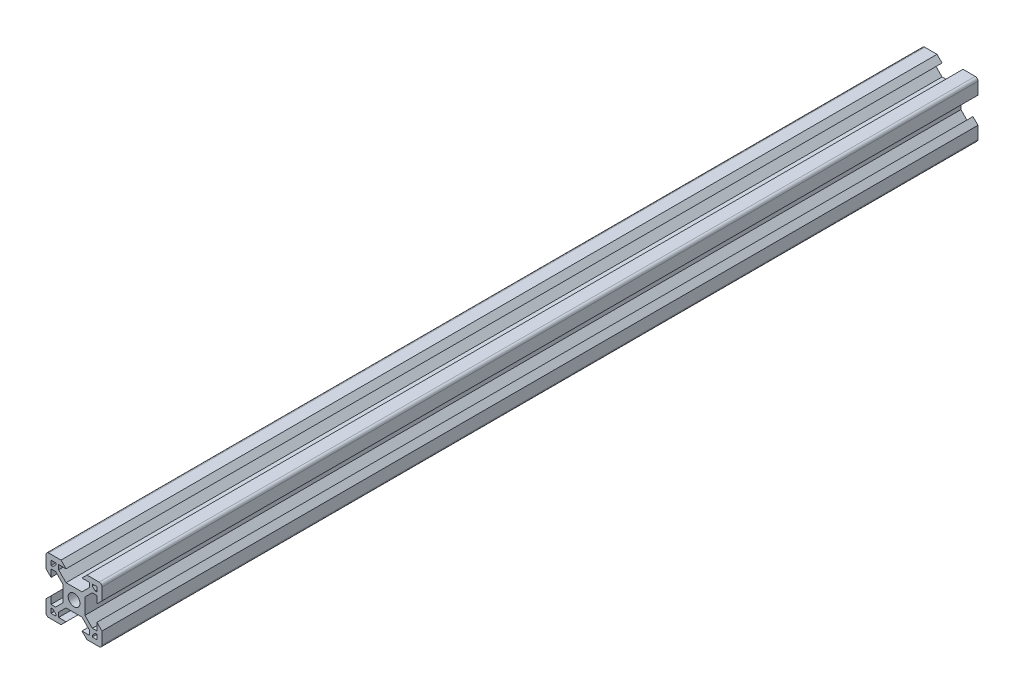
from build123d import *

# Parameters (mm, degrees)
SKETCH1_R           = 2.1
BOSS_EXTRUDE1_DEPTH = 313


with BuildPart() as part:
    # Sketch1 → Boss-Extrude1 (new body)
    with BuildSketch(Plane.XY):
        with BuildLine():
            Line((0, 1), (0, 5.36))
            Line((0, 5.36), (1.8, 7.16))
            Line((1.8, 7.16), (1.8, 4.500660172))
            Line((1.8, 4.500660172), (3.44, 4.500660172))
            Line((3.44, 4.500660172), (6.099339828, 7.16))
            Line((6.099339828, 7.16), (6.099339828, 12.84))
            Line((6.099339828, 12.84), (3.44, 15.499339828))
            Line((3.44, 15.499339828), (1.8, 15.499339828))
            Line((1.8, 15.499339828), (1.8, 12.84))
            Line((1.8, 12.84), (0, 14.64))
            Line((0, 14.64), (0, 19))
            ThreePointArc((0, 19), (0.292893219, 19.707106781), (1, 20))
            Line((1, 20), (5.36, 20))
            Line((5.36, 20), (7.16, 18.2))
            Line((7.16, 18.2), (4.500660172, 18.2))
            Line((4.500660172, 18.2), (4.500660172, 16.56))
            Line((4.500660172, 16.56), (7.16, 13.900660172))
            Line((7.16, 13.900660172), (12.84, 13.900660172))
            Line((12.84, 13.900660172), (15.464579042, 16.525239214))
            Line((15.464579042, 16.525239214), (15.464579042, 18.165239214))
            Line((15.464579042, 18.165239214), (12.84, 18.2))
            Line((12.84, 18.2), (14.64, 20))
            Line((14.64, 20), (19, 20))
            ThreePointArc((19, 20), (19.707106781, 19.707106781), (20, 19))
            Line((20, 19), (20, 14.674581351))
            Line((20, 14.674581351), (18.155899385, 12.84))
            Line((18.155899385, 12.84), (18.155899385, 15.455239214))
            Line((18.155899385, 15.455239214), (16.515899385, 15.455239214))
            Line((16.515899385, 15.455239214), (13.900660172, 12.84))
            Line((13.900660172, 12.84), (13.900660172, 7.16))
            Line((13.900660172, 7.16), (16.56, 4.500660172))
            Line((16.56, 4.500660172), (18.2, 4.500660172))
            Line((18.2, 4.500660172), (18.2, 7.16))
            Line((18.2, 7.16), (20, 5.36))
            Line((20, 5.36), (20, 1))
            ThreePointArc((20, 1), (19.707106781, 0.292893219), (19, 0))
            Line((19, 0), (14.64, 0))
            Line((14.64, 0), (12.84, 1.8))
            Line((12.84, 1.8), (15.499339828, 1.8))
            Line((15.499339828, 1.8), (15.499339828, 3.44))
            Line((15.499339828, 3.44), (12.84, 6.099339828))
            Line((12.84, 6.099339828), (7.16, 6.099339828))
            Line((7.16, 6.099339828), (4.500660172, 3.44))
            Line((4.500660172, 3.44), (4.500660172, 1.8))
            Line((4.500660172, 1.8), (7.16, 1.8))
            Line((7.16, 1.8), (5.36, 0))
            Line((5.36, 0), (1, 0))
            ThreePointArc((1, 0), (0.292893219, 0.292893219), (0, 1))
        make_face()
        with Locations((10.02040103, 9.97959897)):
            Circle(SKETCH1_R, mode=Mode.SUBTRACT)
        Polygon((16.534579042, 18.2), (16.534579042, 17.576559557), (17.585899385, 16.525239214), (18.2, 16.525239214), (18.2, 18.2), align=None, mode=Mode.SUBTRACT)
        Polygon((18.2, 1.75919794), (18.2, 3.433958726), (17.585899385, 3.433958726), (16.534579042, 2.382638382), (16.534579042, 1.75919794), align=None, mode=Mode.SUBTRACT)
        Polygon((2.454902675, 16.525239214), (1.84080206, 16.525239214), (1.84080206, 18.2), (3.506223018, 18.2), (3.506223018, 17.576559557), align=None, mode=Mode.SUBTRACT)
        Polygon((3.506223018, 1.75919794), (1.84080206, 1.75919794), (1.84080206, 3.433958726), (2.454902675, 3.433958726), (3.506223018, 2.382638382), align=None, mode=Mode.SUBTRACT)
    extrude(amount=-BOSS_EXTRUDE1_DEPTH)


solid = part.part
